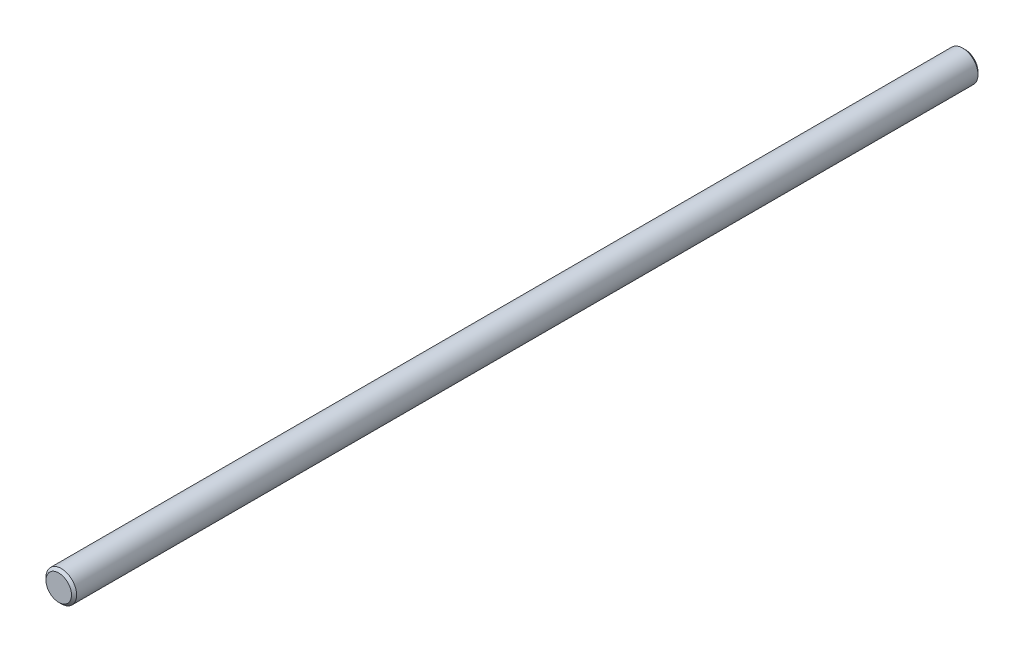
from build123d import *

# Parameters (mm, degrees)
SCHIZZO1_R                   = 6
ESTRUSIONE_ESTRUSIONE1_DEPTH = 355
SMUSSO1_SIZE                 = 1


with BuildPart() as part:
    # Schizzo1 → Estrusione-Estrusione1 (new body)
    with BuildSketch(Plane.XY):
        Circle(SCHIZZO1_R)
    extrude(amount=ESTRUSIONE_ESTRUSIONE1_DEPTH)

    # Smusso1
    smusso1_edges = [part.edges().sort_by_distance(p)[0] for p in [
        (-6, 0, 0),
        (-6, 0, 355),
    ]]
    chamfer(smusso1_edges, length=SMUSSO1_SIZE)


solid = part.part
